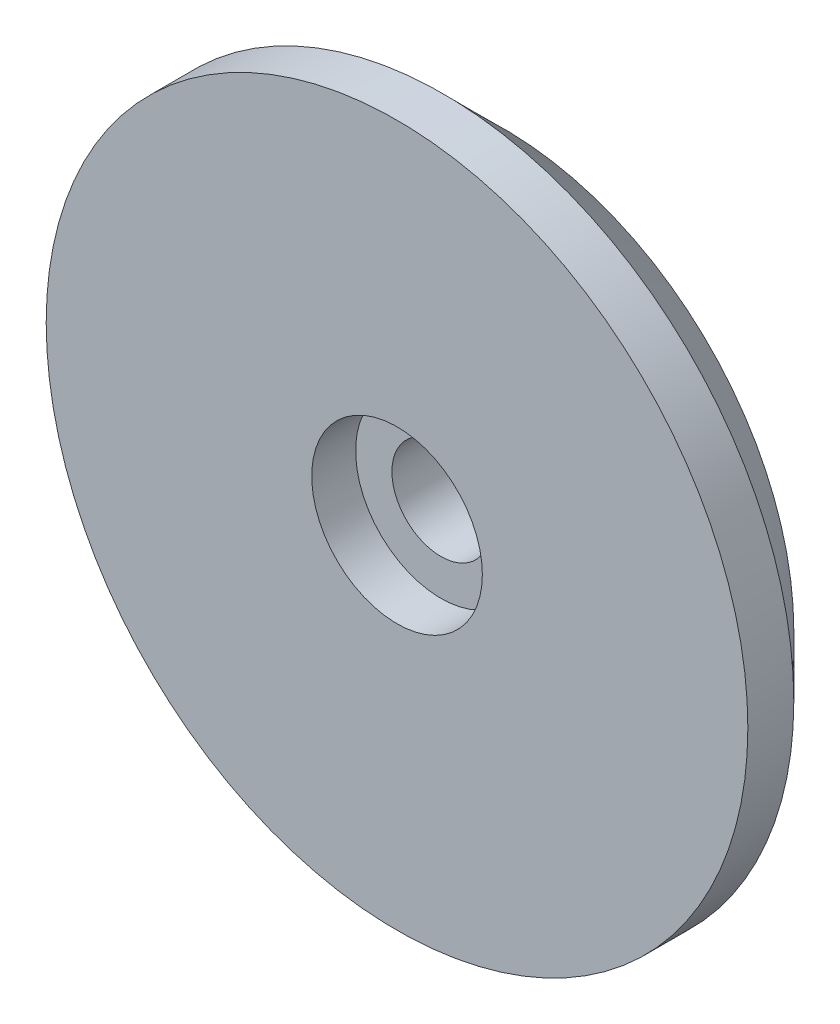
from build123d import *

# Parameters (mm, degrees)
SKETCH2_R                = 17.181172962
BOSS_EXTRUDE1_DEPTH      = 1.25
BOSS_EXTRUDE1_DEPTH_BACK = 4
SKETCH3_R                = 14.079134115
SKETCH3_R_2              = 5.629774077
CUT_EXTRUDE1_DEPTH       = 2.25
SKETCH4_R                = 2.4
CUT_EXTRUDE2_DEPTH       = 12.25
SKETCH5_R                = 4.178678746
CUT_EXTRUDE3_DEPTH       = 2.15
CHAMFER1_SIZE            = 3
SCALE2_SCALE             = 0.75


with BuildPart() as part:
    # Sketch2 → Boss-Extrude1 (new body, two sides)
    with BuildSketch(Plane.XY.offset(-466.775167308)) as boss_extrude1_sk:
        Circle(SKETCH2_R)
    extrude(amount=BOSS_EXTRUDE1_DEPTH)
    extrude(boss_extrude1_sk.sketch, amount=-BOSS_EXTRUDE1_DEPTH_BACK)

    # Sketch3 → Cut-Extrude1 (cut)
    with BuildSketch(Plane(origin=(0, 0, -470.775167308), x_dir=(-1, 0, 0), z_dir=(0, 0, -1))):
        Circle(SKETCH3_R)
        Circle(SKETCH3_R_2, mode=Mode.SUBTRACT)
    extrude(amount=-CUT_EXTRUDE1_DEPTH, mode=Mode.SUBTRACT)

    # Sketch4 → Cut-Extrude2 (cut)
    with BuildSketch(Plane(origin=(0, 0, -470.775167308), x_dir=(-1, 0, 0), z_dir=(0, 0, -1))):
        Circle(SKETCH4_R)
    extrude(amount=-CUT_EXTRUDE2_DEPTH, mode=Mode.SUBTRACT)

    # Sketch5 → Cut-Extrude3 (cut)
    with BuildSketch(Plane.XY.offset(-465.525167308)):
        Circle(SKETCH5_R)
    extrude(amount=-CUT_EXTRUDE3_DEPTH, mode=Mode.SUBTRACT)

    # Chamfer1
    chamfer1_edges = [part.edges().sort_by_distance(p)[0] for p in [
        (-17.181172962, 0, -470.775167308),
    ]]
    chamfer(chamfer1_edges, length=CHAMFER1_SIZE)


with BuildPart() as part_1:
    # Scale2: scaled about (0, 0, -467.372549258)
    add(part.part.scale(SCALE2_SCALE).moved(Location((0, 0, -116.843137314))))


solid = part_1.part
